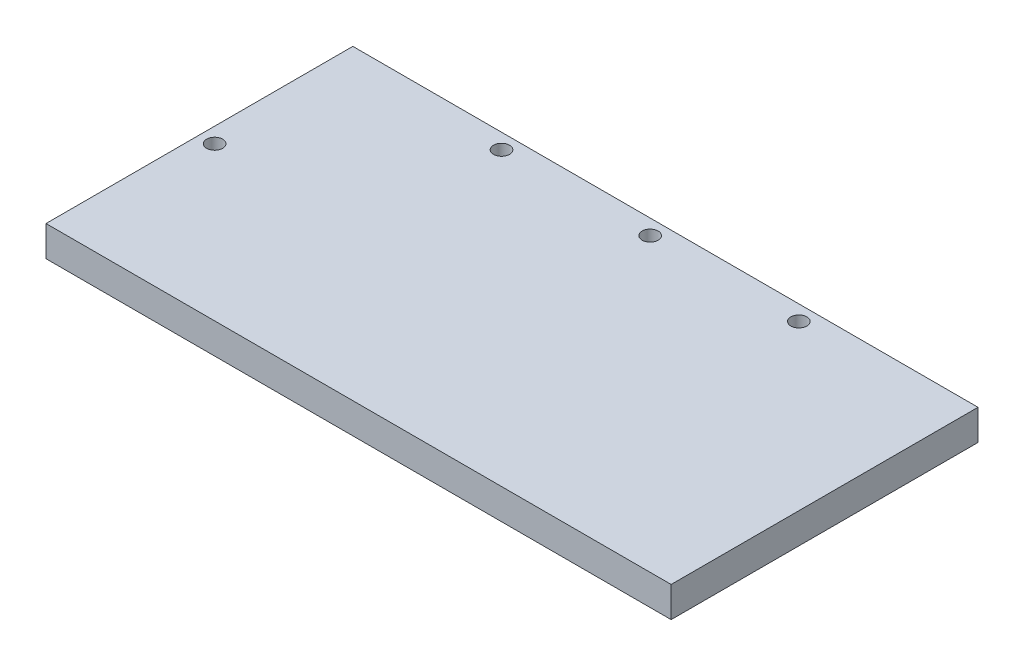
from build123d import *

# Parameters (mm, degrees)
SKETCH1_W           = 164
SKETCH1_H           = 80.5
SKETCH1_R           = 2.1
BOSS_EXTRUDE1_DEPTH = 8


with BuildPart() as part:
    # Sketch1 → Boss-Extrude1 (new body)
    with BuildSketch(Plane(origin=(0, 0, 0), x_dir=(1, 0, 0), z_dir=(0, 1, 0))):
        Rectangle(SKETCH1_W, SKETCH1_H)
        with Locations((0, 36.25)):
            Circle(SKETCH1_R, mode=Mode.SUBTRACT)
        with Locations((39, 36.25)):
            Circle(SKETCH1_R, mode=Mode.SUBTRACT)
        with Locations((-39, 36.25)):
            Circle(SKETCH1_R, mode=Mode.SUBTRACT)
        with Locations((-78, 0)):
            Circle(SKETCH1_R, mode=Mode.SUBTRACT)
    extrude(amount=BOSS_EXTRUDE1_DEPTH)


solid = part.part
